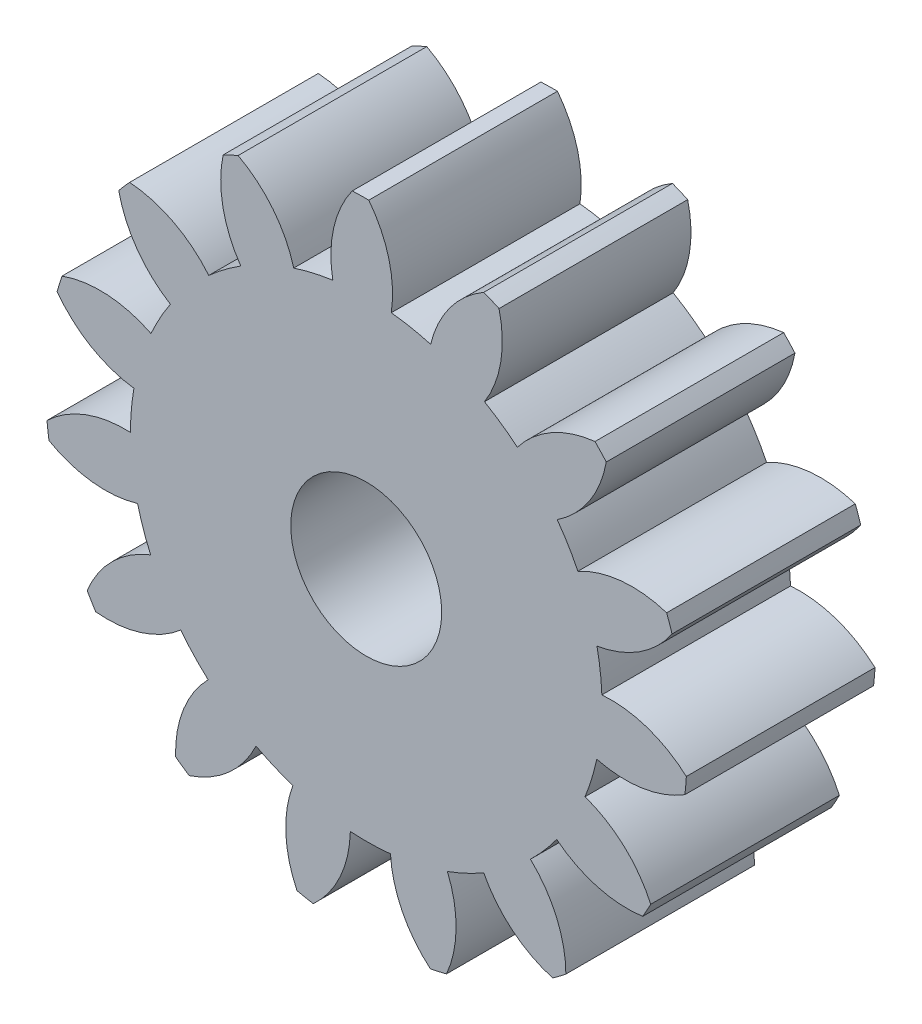
from build123d import *

# Parameters (mm, degrees)
MODEL_R             = 2
BOSS_EXTRUDE1_DEPTH = 5


with BuildPart() as part:
    # Model → Boss-Extrude1 (new body)
    with BuildSketch(Plane.XY):
        with BuildLine():
            ThreePointArc((455.213810884, 475.737053866), (455.579522306, 476.123501007), (455.911034715, 476.539656939))
            ThreePointArc((455.911034715, 476.539656939), (456.985627664, 475.992517671), (458.188848778, 475.912703304))
            ThreePointArc((458.188848778, 475.912703304), (458.297616539, 476.103235845), (458.401430664, 476.296512079))
            ThreePointArc((458.401430664, 476.296512079), (457.695483937, 477.274137059), (456.66162305, 477.894816565))
            ThreePointArc((456.66162305, 477.894816565), (456.838534846, 478.396601831), (456.972120634, 478.911617437))
            ThreePointArc((456.972120634, 478.911617437), (458.176351731, 478.848857172), (459.308012342, 479.265337237))
            ThreePointArc((459.308012342, 479.265337237), (459.329880069, 479.483637208), (459.346106466, 479.702428842))
            ThreePointArc((459.346106466, 479.702428842), (458.303556137, 480.3083993), (457.106624121, 480.454909137))
            ThreePointArc((457.106624121, 480.454909137), (457.064146634, 480.985269298), (456.976707605, 481.5100937))
            ThreePointArc((456.976707605, 481.5100937), (458.102354353, 481.942564259), (458.96678006, 482.783325568))
            ThreePointArc((458.96678006, 482.783325568), (458.897966625, 482.991646922), (458.823799602, 483.198122895))
            ThreePointArc((458.823799602, 483.198122895), (457.624912095, 483.327661034), (456.471869369, 482.974668319))
            ThreePointArc((456.471869369, 482.974668319), (456.217347342, 483.441899284), (455.9240025, 483.885785577))
            ThreePointArc((455.9240025, 483.885785577), (456.776430349, 484.73870887), (457.224154095, 485.858376156))
            ThreePointArc((457.224154095, 485.858376156), (457.076557966, 486.020698236), (456.924821674, 486.179156978))
            ThreePointArc((456.924821674, 486.179156978), (455.776895531, 485.809864476), (454.867113658, 485.018404858))
            ThreePointArc((454.867113658, 485.018404858), (454.444556262, 485.341718149), (453.996027593, 485.627914358))
            ThreePointArc((453.996027593, 485.627914358), (454.427844026, 486.753812201), (454.381450307, 487.958784817))
            ThreePointArc((454.381450307, 487.958784817), (454.180592196, 488.047040662), (453.977523219, 488.130083216))
            ThreePointArc((453.977523219, 488.130083216), (453.079045297, 487.325814102), (452.569833828, 486.232738138))
            ThreePointArc((452.569833828, 486.232738138), (452.052305076, 486.35622995), (451.526147262, 486.435250151))
            ThreePointArc((451.526147262, 486.435250151), (451.462687294, 487.639444578), (450.930198006, 488.721371813))
            ThreePointArc((450.930198006, 488.721371813), (450.710808105, 488.720301185), (450.491518914, 488.713568739))
            ThreePointArc((450.491518914, 488.713568739), (449.997844209, 487.613388449), (449.977250433, 486.407698904))
            ThreePointArc((449.977250433, 486.407698904), (449.454235747, 486.31001638), (448.941426255, 486.168197264))
            ThreePointArc((448.941426255, 486.168197264), (448.393662691, 487.242472118), (447.467150069, 488.014278923))
            ThreePointArc((447.467150069, 488.014278923), (447.267162884, 487.924066944), (447.069570573, 487.828723599))
            ThreePointArc((447.069570573, 487.828723599), (447.066059926, 486.622863301), (447.537644694, 485.51303485))
            ThreePointArc((447.537644694, 485.51303485), (447.099578065, 485.211068187), (446.688786314, 484.872931566))
            ThreePointArc((446.688786314, 484.872931566), (445.751432451, 485.631534965), (444.591098944, 485.959768933))
            ThreePointArc((444.591098944, 485.959768933), (444.445094078, 485.796014074), (444.303364151, 485.62854556))
            ThreePointArc((444.303364151, 485.62854556), (444.790624586, 484.525509454), (445.672846607, 483.703441519))
            ThreePointArc((445.672846607, 483.703441519), (445.395473735, 483.249403495), (445.157729351, 482.773416263))
            ThreePointArc((445.157729351, 482.773416263), (443.992862186, 483.085178789), (442.79934, 482.913085284))
            ThreePointArc((442.79934, 482.913085284), (442.732563019, 482.704102247), (442.67120187, 482.493465393))
            ThreePointArc((442.67120187, 482.493465393), (443.56498163, 481.683978441), (444.705296702, 481.291814037))
            ThreePointArc((444.705296702, 481.291814037), (444.636577876, 480.764211952), (444.612989023, 480.232676626))
            ThreePointArc((444.612989023, 480.232676626), (443.422024673, 480.043691705), (442.401684635, 479.401027258))
            ThreePointArc((442.401684635, 479.401027258), (442.425681887, 479.182951108), (442.455299415, 478.965566939))
            ThreePointArc((442.455299415, 478.965566939), (443.60105586, 478.589596791), (444.802293147, 478.695144705))
            ThreePointArc((444.802293147, 478.695144705), (444.954110477, 478.185205752), (445.148755882, 477.690029618))
            ThreePointArc((445.148755882, 477.690029618), (444.137622902, 477.03297446), (443.466891075, 476.030861592))
            ThreePointArc((443.466891075, 476.030861592), (443.577513216, 475.841399678), (443.692988281, 475.654855892))
            ThreePointArc((443.692988281, 475.654855892), (444.892609713, 475.777411201), (445.947064377, 476.36242124))
            ThreePointArc((445.947064377, 476.36242124), (446.293167267, 475.958318498), (446.67239097, 475.585122008))
            ThreePointArc((446.67239097, 475.585122008), (446.015923439, 474.573607419), (445.810775449, 473.385320549))
            ThreePointArc((445.810775449, 473.385320549), (445.988894907, 473.257232556), (446.170260821, 473.133784268))
            ThreePointArc((446.170260821, 473.133784268), (447.216321796, 473.733674108), (447.941669045, 474.696992722))
            ThreePointArc((447.941669045, 474.696992722), (448.422213161, 474.468599225), (448.92044394, 474.281911443))
            ThreePointArc((448.92044394, 474.281911443), (448.732151056, 473.090837485), (449.028058855, 471.921842207))
            ThreePointArc((449.028058855, 471.921842207), (449.242877156, 471.877275714), (449.458774107, 471.838268254))
            ThreePointArc((449.458774107, 471.838268254), (450.170401179, 472.811766221), (450.441221884, 473.986826871))
            ThreePointArc((450.441221884, 473.986826871), (450.973116782, 473.973633929), (451.504206009, 474.005734869))
            ThreePointArc((451.504206009, 474.005734869), (451.816645324, 472.84104905), (452.562443764, 471.893475269))
            ThreePointArc((452.562443764, 471.893475269), (452.776816874, 471.940136226), (452.989914315, 471.992314338))
            ThreePointArc((452.989914315, 471.992314338), (453.244060699, 473.171093791), (453.0135275, 474.354717814))
            ThreePointArc((453.0135275, 474.354717814), (453.504803721, 474.559006608), (453.976921244, 474.804345725))
            ThreePointArc((453.976921244, 474.804345725), (454.736069161, 473.867432804), (455.802802917, 473.305124634))
            ThreePointArc((455.802802917, 473.305124634), (455.979663777, 473.434944938), (456.153115226, 473.569286554))
            ThreePointArc((456.153115226, 473.569286554), (455.905836703, 474.749525816), (455.213810884, 475.737053866))
        make_face()
        with Locations((450.861979287, 480.22164557)):
            Circle(MODEL_R, mode=Mode.SUBTRACT)
    extrude(amount=BOSS_EXTRUDE1_DEPTH)


solid = part.part
